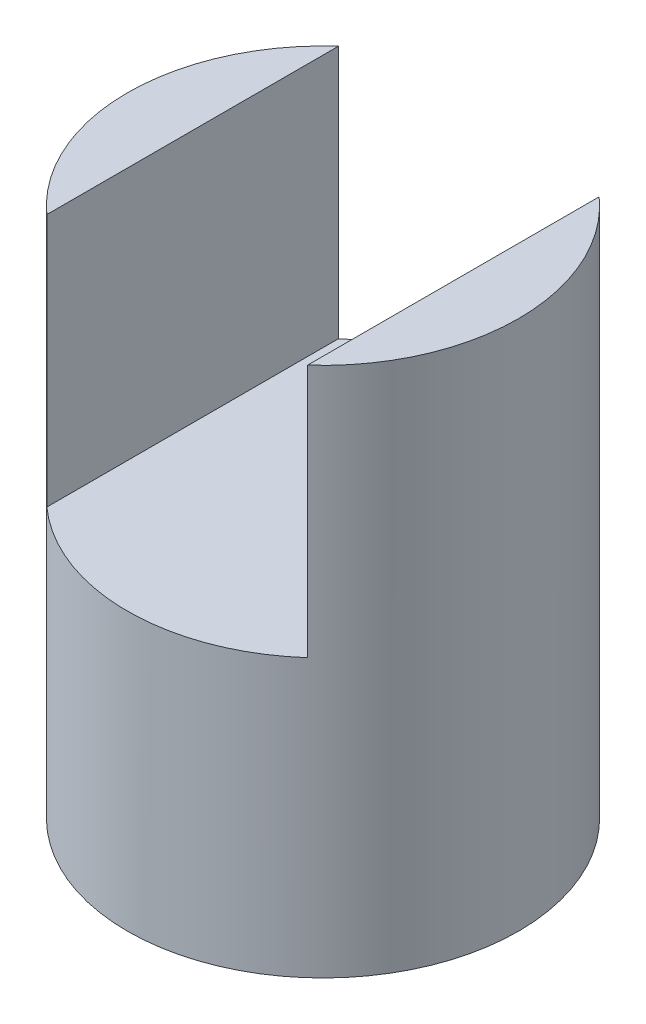
from build123d import *

# Parameters (mm, degrees)
SKETCH1_R               = 9.525
BOSS_EXTRUDE1_DEPTH     = 12.5
CUT_EXTRUDE1_REACH      = 20.377
SKETCH2_R               = 3
SKETCH3_R               = 9.525
BOSS_EXTRUDE2_DEPTH     = 13.3375
CUT_EXTRUDE2_DEPTH      = 13.3375
CUT_EXTRUDE2_DEPTH_BACK = 13.3375
SKETCH4_W               = 12.7
SKETCH4_H               = 12.3375
SKETCH5_R               = 2.413
CUT_EXTRUDE4_DEPTH      = 13.3375


with BuildPart() as part:
    # Sketch1 → Boss-Extrude1 (new body)
    with BuildSketch(Plane(origin=(0, 0, 0), x_dir=(1, 0, 0), z_dir=(0, 1, 0))):
        Circle(SKETCH1_R)
    extrude(amount=BOSS_EXTRUDE1_DEPTH)

    # Sketch2 → Cut-Extrude1 (cut, up to next)
    with BuildSketch(Plane(origin=(0, 12.5, 0), x_dir=(1, 0, 0), z_dir=(0, 1, 0)), mode=Mode.PRIVATE) as cut_extrude1_sk1:
        Circle(SKETCH2_R)
    cut_extrude1_tool1 = extrude(cut_extrude1_sk1.sketch, amount=-CUT_EXTRUDE1_REACH, mode=Mode.PRIVATE) & part.part
    add(cut_extrude1_tool1.solids().sort_by_distance((0, 12.5, 0))[0], mode=Mode.SUBTRACT)

    # Sketch3 → Boss-Extrude2 (add)
    with BuildSketch(Plane(origin=(0, 12.5, 0), x_dir=(1, 0, 0), z_dir=(0, 1, 0))):
        Circle(SKETCH3_R)
    extrude(amount=BOSS_EXTRUDE2_DEPTH)

    # Sketch4 → Cut-Extrude2 (cut, two sides: drawn at the far end of the back side and taken through both)
    with BuildSketch(Plane.XY.offset(-CUT_EXTRUDE2_DEPTH_BACK)):
        with Locations((0, 19.66875)):
            Rectangle(SKETCH4_W, SKETCH4_H)
    extrude(amount=CUT_EXTRUDE2_DEPTH + CUT_EXTRUDE2_DEPTH_BACK, mode=Mode.SUBTRACT)

    # Sketch5 → Cut-Extrude4 (cut)
    with BuildSketch(Plane.XY):
        with Locations((0, 9.944)):
            Circle(SKETCH5_R)
    extrude(amount=-CUT_EXTRUDE4_DEPTH, mode=Mode.SUBTRACT)


solid = part.part
